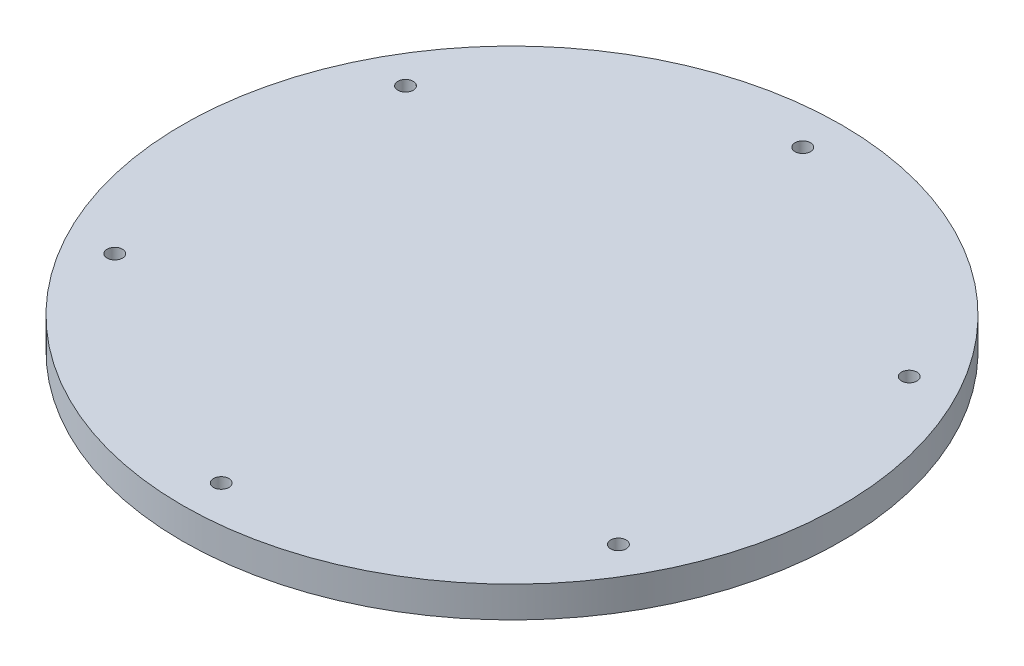
from build123d import *

# Parameters (mm, degrees)
SKETCH_1_R          = 85
EXTRUDE_1_DEPTH     = 8
SKETCH_2_R          = 2
CUT_EXTRUDE_1_DEPTH = 9


with BuildPart() as part:
    # 草图1 → 凸台-拉伸1 (new body)
    with BuildSketch(Plane(origin=(0, 0, 0), x_dir=(1, 0, 0), z_dir=(0, 1, 0))):
        Circle(SKETCH_1_R)
    extrude(amount=EXTRUDE_1_DEPTH)

    # 草图2 → 切除-拉伸1 (cut, through all)
    with BuildSketch(Plane(origin=(0, 8, 0), x_dir=(1, 0, 0), z_dir=(0, 1, 0))):
        with Locations((0, -75)):
            Circle(SKETCH_2_R)
        with Locations((-64.951905284, -37.5)):
            Circle(SKETCH_2_R)
        with Locations((-64.951905284, 37.5)):
            Circle(SKETCH_2_R)
        with Locations((0, 75)):
            Circle(SKETCH_2_R)
        with Locations((64.951905284, 37.5)):
            Circle(SKETCH_2_R)
        with Locations((64.951905284, -37.5)):
            Circle(SKETCH_2_R)
    extrude(amount=-CUT_EXTRUDE_1_DEPTH, mode=Mode.SUBTRACT)


solid = part.part
